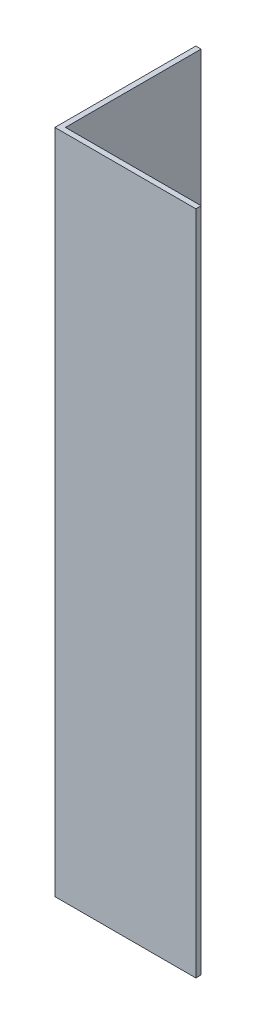
from build123d import *

# Parameters (mm, degrees)
EXTRUDE_1_DEPTH = 94.5


with BuildPart() as part:
    # Эскиз1 → Бобышка-Вытянуть1 (new body)
    with BuildSketch(Plane(origin=(0, 0, 0), x_dir=(1, 0, 0), z_dir=(0, 1, 0))):
        Polygon((0, 0), (0, 20), (0.75, 20), (0.75, 0.75), (20, 0.75), (20, 0), align=None)
    extrude(amount=EXTRUDE_1_DEPTH)


solid = part.part
